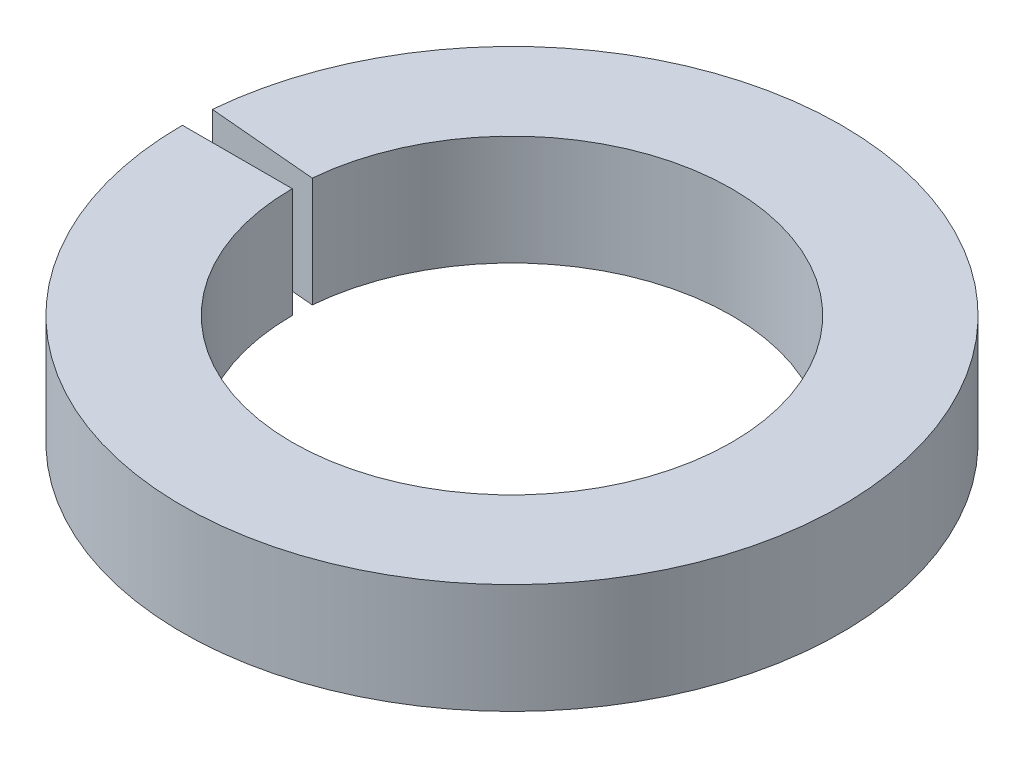
from build123d import *

# Parameters (mm, degrees)
SKETCH1_W      = 3.175
SKETCH1_H      = 3.175
REVOLVE1_ANGLE = 355


with BuildPart() as part:
    # Sketch1 → Revolve1 (revolve)
    with BuildSketch(Plane.XY):
        with Locations((-7.9375, 1.5875)):
            Rectangle(SKETCH1_W, SKETCH1_H)
    revolve(axis=Axis((0, 0, 0), (0, 1, 0)), revolution_arc=REVOLVE1_ANGLE)


solid = part.part
